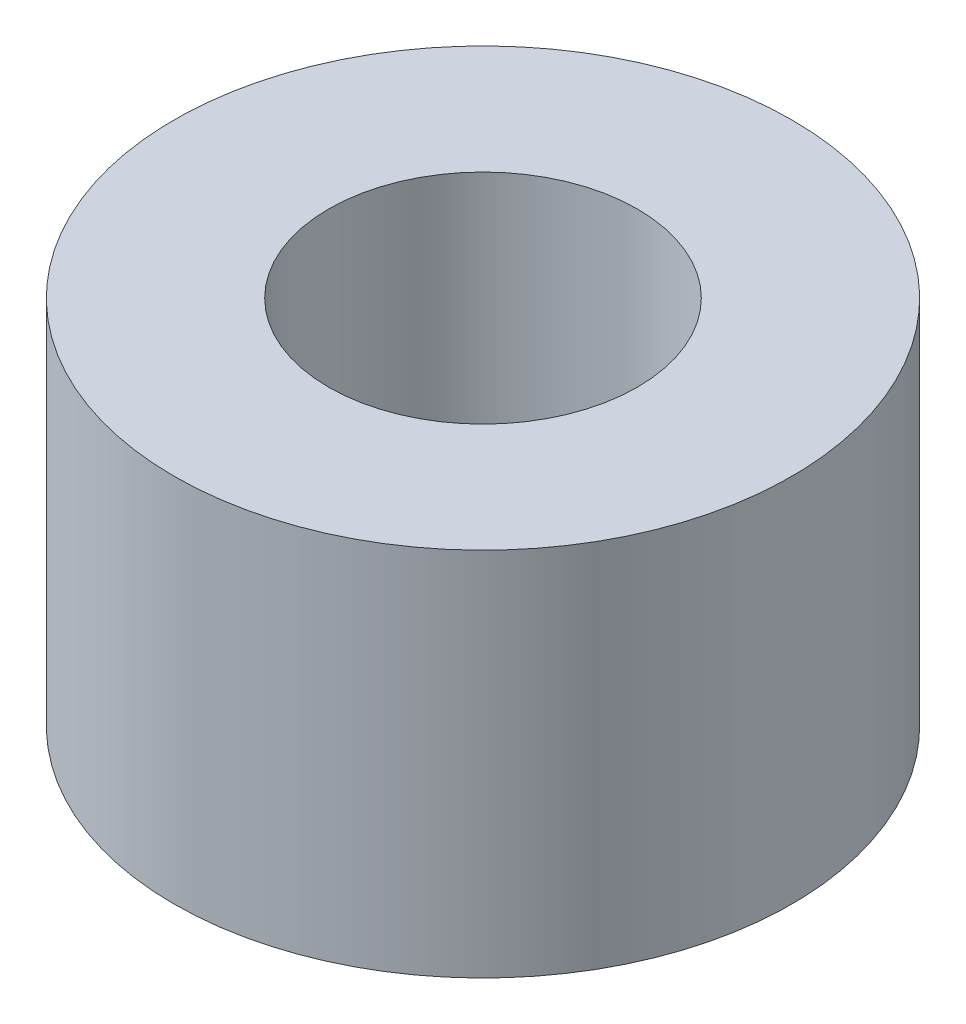
from build123d import *

# Parameters (mm, degrees)
SKETCH1_R                = 5
SKETCH1_R_2              = 2.5
BOSS_EXTRUDE1_DEPTH      = 3
BOSS_EXTRUDE1_DEPTH_BACK = 2
SKETCH2_R                = 5
BOSS_EXTRUDE2_DEPTH      = 1
SKETCH3_R                = 1.15
CUT_EXTRUDE1_DEPTH       = 1


with BuildPart() as part:
    # Sketch1 → Boss-Extrude1 (new body, two sides)
    with BuildSketch(Plane(origin=(0, 0, 0), x_dir=(1, 0, 0), z_dir=(0, 1, 0))) as boss_extrude1_sk:
        Circle(SKETCH1_R)
        Circle(SKETCH1_R_2, mode=Mode.SUBTRACT)
    extrude(amount=BOSS_EXTRUDE1_DEPTH)
    extrude(boss_extrude1_sk.sketch, amount=-BOSS_EXTRUDE1_DEPTH_BACK)

    # Sketch2 → Boss-Extrude2 (add)
    with BuildSketch(Plane.XZ.offset(2)):
        Circle(SKETCH2_R)
    extrude(amount=BOSS_EXTRUDE2_DEPTH)

    # Sketch3 → Cut-Extrude1 (cut)
    with BuildSketch(Plane.XZ.offset(3)):
        Circle(SKETCH3_R)
    extrude(amount=-CUT_EXTRUDE1_DEPTH, mode=Mode.SUBTRACT)


solid = part.part
